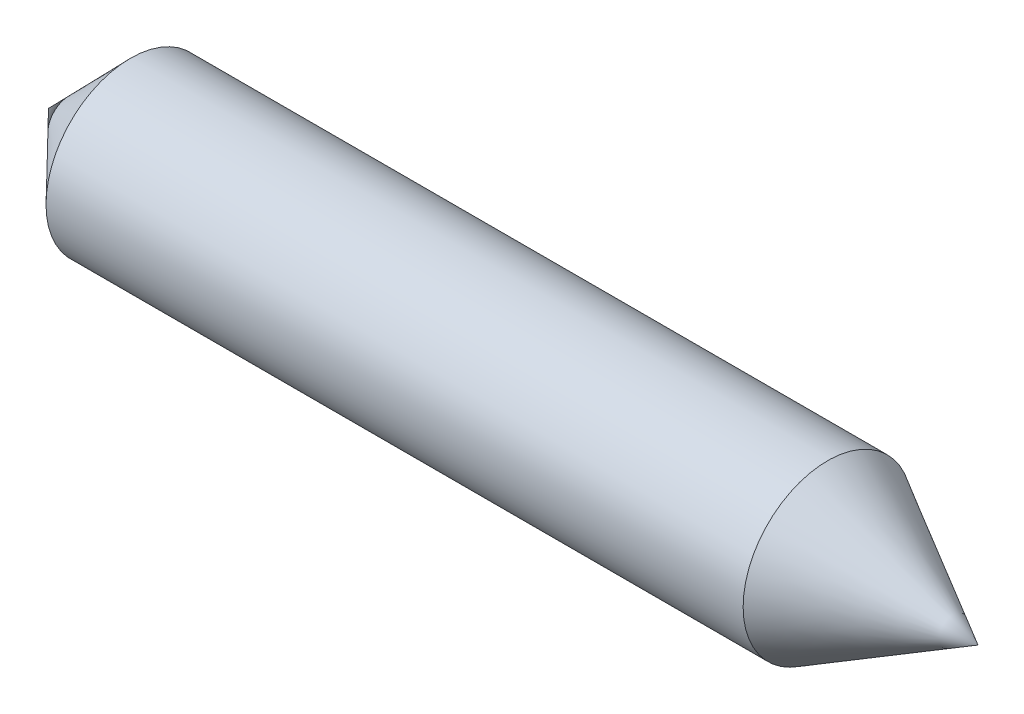
from build123d import *


with BuildPart() as part:
    # Croquis1 → Revolución2 (revolve)
    with BuildSketch(Plane.XY):
        Polygon((-79.053152984, 7.18483977), (120.946847016, 7.18483977), (88.590740478, 25.363302575), (-61.409259522, 25.363302575), align=None)
    revolve(axis=Axis((-79.053152984, 7.18483977, 0), (1, 0, 0)))


solid = part.part
